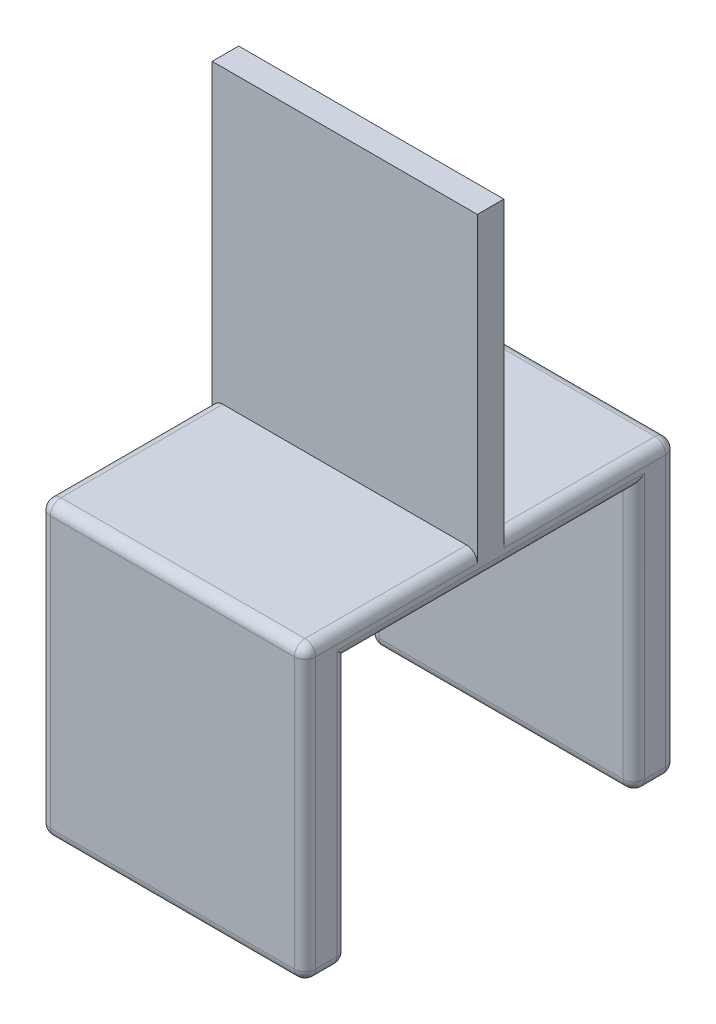
from build123d import *

# Parameters (mm, degrees)
SKETCH1_W           = 50
SKETCH1_H           = 55
BOSS_EXTRUDE1_DEPTH = 5
SKETCH2_W           = 50
SKETCH2_H           = 70
BOSS_EXTRUDE2_DEPTH = 5
SKETCH3_W           = 50
SKETCH3_H           = 8
BOSS_EXTRUDE3_DEPTH = 50
FILLET1_R           = 2


with BuildPart() as part:
    # Sketch1 → Boss-Extrude1 (new body)
    with BuildSketch(Plane.XY):
        with Locations((-25, 27.5)):
            Rectangle(SKETCH1_W, SKETCH1_H)
    extrude(amount=BOSS_EXTRUDE1_DEPTH)

    # Sketch2 → Boss-Extrude2 (add)
    with BuildSketch(Plane(origin=(0, 0, 0), x_dir=(1, 0, 0), z_dir=(0, 1, 0))):
        with Locations((-25, -2.5)):
            Rectangle(SKETCH2_W, SKETCH2_H)
    extrude(amount=-BOSS_EXTRUDE2_DEPTH)

    # Sketch3 → Boss-Extrude3 (add)
    with BuildSketch(Plane(origin=(0, -5, 0), x_dir=(-1, 0, 0), z_dir=(0, -1, 0))):
        with Locations((25, -33.5)):
            Rectangle(SKETCH3_W, SKETCH3_H)
        with Locations((25, 28.5)):
            Rectangle(SKETCH3_W, SKETCH3_H)
    extrude(amount=BOSS_EXTRUDE3_DEPTH)

    # Fillet1
    fillet1_edges = [part.edges().sort_by_distance(p)[0] for p in [
        (-50, 0, 21.25),
        (-25, 0, 37.5),
        (0, 0, 21.25),
        (-50, -27.5, 37.5),
        (-50, -27.5, -32.5),
        (0, -27.5, -32.5),
        (0, -27.5, 37.5),
        (-50, 0, -16.25),
        (0, 0, -16.25),
        (-25, 0, -32.5),
        (0, -5, 2.5),
        (-50, -30, 29.5),
        (0, -55, 33.5),
        (0, -30, 29.5),
        (-25, -55, 37.5),
        (-25, -55, 29.5),
        (-50, -55, 33.5),
        (-50, -5, 2.5),
        (-25, -55, -24.5),
        (0, -30, -24.5),
        (-50, -55, -28.5),
        (-50, -30, -24.5),
        (-25, -55, -32.5),
        (0, -55, -28.5),
    ]]
    fillet(fillet1_edges, radius=FILLET1_R)


solid = part.part
